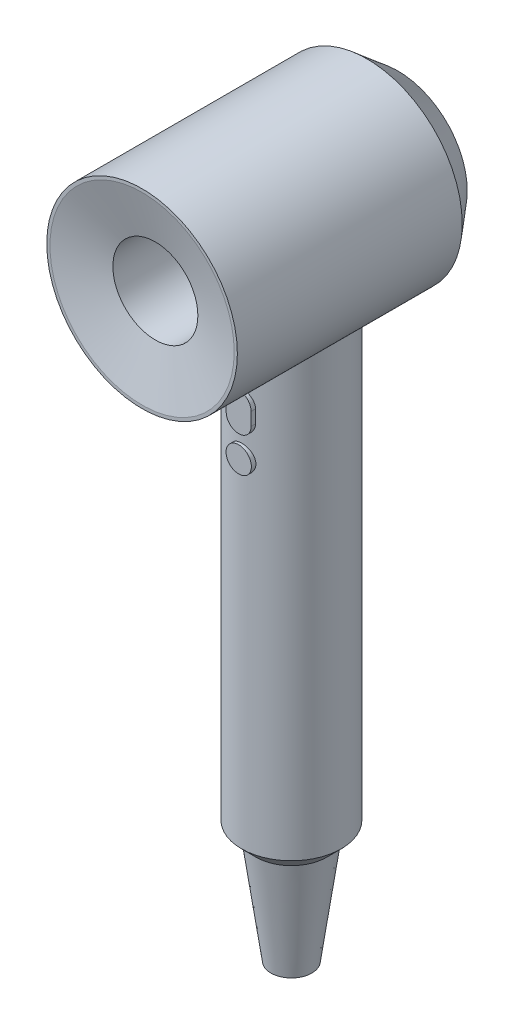
from build123d import *

# Parameters (mm, degrees)
SKETCH2_R             = 36.482650196
SKETCH2_R_2           = 16.269737134
BOSS_EXTRUDE1_DEPTH   = 98
SKETCH5_R             = 4.846018297
BOSS_EXTRUDE2_DEPTH   = 21
BOSS_EXTRUDE2_2_DEPTH = 21
CHAMFER1_SIZE         = 19
CHAMFER1_SIZE2        = 5.091034656
CHAMFER2_SIZE         = 10
CHAMFER2_SIZE2        = 11.917535926


with BuildPart() as part:
    # Sketch2 → Boss-Extrude1 (new body)
    with BuildSketch(Plane.XY):
        with Locations((0, 248.274519969)):
            Circle(SKETCH2_R)
        with Locations((0, 248.274519969)):
            Circle(SKETCH2_R_2, mode=Mode.SUBTRACT)
    extrude(amount=BOSS_EXTRUDE1_DEPTH)

    # Sketch4 → Revolve1 (revolve)
    with BuildSketch(Plane(origin=(0, 0, 0), x_dir=(0, 0, -1), z_dir=(1, 0, 0))):
        Polygon((-59.909549302, 217.756891216), (-59.909549302, 46.820189579), (-54.370591176, 41.281231453), (-48.661476805, 0), (-40.831329813, 0), (-40.831329813, 217.756891216), align=None)
    revolve(axis=Axis((0, 217.756891216, 40.831329813), (0, -1, 0)))

    # Chamfer1
    chamfer1_edges = [part.edges().sort_by_distance(p)[0] for p in [
        (-16.269737134, 248.274519969, 98),
    ]]
    chamfer1_side = [part.faces().sort_by_distance(p)[0] for p in [
        (-35.450765022, 248.274519969, 98),
    ]]
    chamfer(chamfer1_edges, length=CHAMFER1_SIZE, length2=CHAMFER1_SIZE2, reference=chamfer1_side[0])

    # Chamfer2
    chamfer2_edges = [part.edges().sort_by_distance(p)[0] for p in [
        (-36.482650196, 248.274519969, 0),
    ]]
    chamfer2_side = [part.faces().sort_by_distance(p)[0] for p in [
        (-35.450765022, 248.274519969, 0),
    ]]
    chamfer(chamfer2_edges, length=CHAMFER2_SIZE, length2=CHAMFER2_SIZE2, reference=chamfer2_side[0])


with BuildPart() as body_2:
    # Sketch5 → Boss-Extrude2 (new body)
    with BuildSketch(Plane.XY.offset(40)):
        with Locations((0, 176.503814228)):
            Circle(SKETCH5_R)
    extrude(amount=BOSS_EXTRUDE2_DEPTH)


with BuildPart() as body_3:
    # Sketch5 → Boss-Extrude2 2 (new body)
    with BuildSketch(Plane.XY.offset(40)):
        with BuildLine():
            Line((4.738091536, 194.743793997), (4.738091536, 189.778466171))
            ThreePointArc((4.738091536, 189.778466171), (-0.024569848, 185.015804787), (-4.787231233, 189.778466171))
            Line((-4.787231233, 189.778466171), (-4.787231233, 194.743793997))
            ThreePointArc((-4.787231233, 194.743793997), (-0.024569848, 199.506455381), (4.738091536, 194.743793997))
        make_face()
    extrude(amount=BOSS_EXTRUDE2_2_DEPTH)


solid = Compound([part.part, body_2.part, body_3.part])
